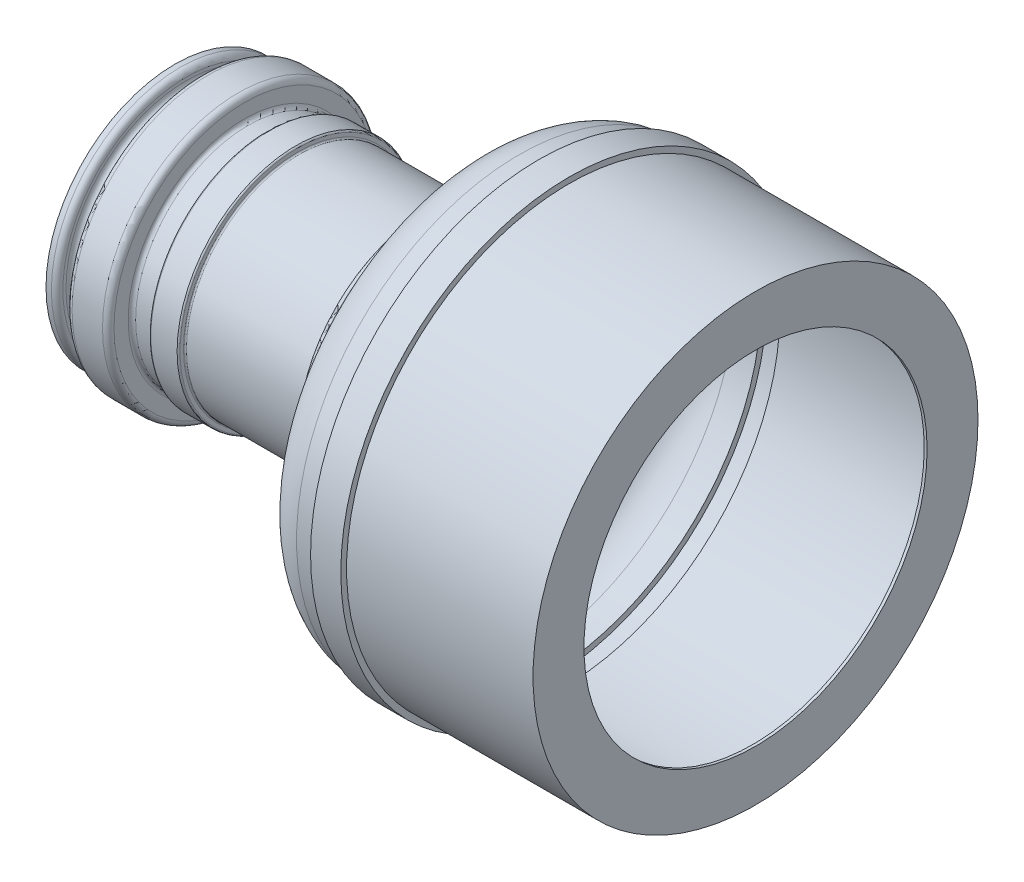
from build123d import *

# Parameters (mm, degrees)
REVOLVE1_ANGLE = 245
REVOLVE2_ANGLE = 245
REVOLVE3_ANGLE = 245
REVOLVE4_ANGLE = 115
SCALE1_SCALE   = 10
SCALE2_SCALE   = 0.75


with BuildPart() as part:
    # Sketch3 → Revolve1 (revolve)
    with BuildSketch(Plane(origin=(0, 0, 0), x_dir=(1, 0, 0), z_dir=(0, 1, 0))):
        with BuildLine():
            Line((18.96, 1.82), (20.82, 1.82))
            Line((20.82, 1.82), (20.82, 22.2))
            Line((20.82, 22.2), (14.72, 22.2))
            ThreePointArc((14.72, 22.2), (13.305786438, 21.614213562), (12.72, 20.2))
            Line((12.72, 20.2), (12.72, 17.4))
            ThreePointArc((12.72, 17.4), (12.134213562, 15.985786438), (10.72, 15.4))
            Line((10.72, 15.4), (-31.78, 15.4))
            ThreePointArc((-31.78, 15.4), (-32.133553391, 15.546446609), (-32.28, 15.9))
            Line((-32.28, 15.9), (-32.28, 17.14))
            ThreePointArc((-32.28, 17.14), (-32.426446609, 17.493553391), (-32.78, 17.64))
            Line((-32.78, 17.64), (-41.88, 17.64))
            ThreePointArc((-41.88, 17.64), (-42.233553391, 17.493553391), (-42.38, 17.14))
            Line((-42.38, 17.14), (-42.38, 16.7))
            ThreePointArc((-42.38, 16.7), (-42.760761184, 15.780761184), (-43.68, 15.4))
            Line((-43.68, 15.4), (-49.42, 15.4))
            ThreePointArc((-49.42, 15.4), (-50.339238816, 15.780761184), (-50.72, 16.7))
            Line((-50.72, 16.7), (-50.72, 21.61))
            ThreePointArc((-50.72, 21.61), (-51.305786438, 23.024213562), (-52.72, 23.61))
            Line((-52.72, 23.61), (-63.27, 23.61))
            ThreePointArc((-63.27, 23.61), (-64.684213562, 23.024213562), (-65.27, 21.61))
            Line((-65.27, 21.61), (-65.27, 18.05))
            ThreePointArc((-65.27, 18.05), (-65.855786438, 16.635786438), (-67.27, 16.05))
            Line((-67.27, 16.05), (-68.95, 16.05))
            ThreePointArc((-68.95, 16.05), (-70.364213562, 16.635786438), (-70.95, 18.05))
            Line((-70.95, 18.05), (-70.95, 19.13))
            ThreePointArc((-70.95, 19.13), (-71.535786438, 20.544213562), (-72.95, 21.13))
            Line((-72.95, 21.13), (-74.81, 21.13))
            Line((-74.81, 21.13), (-74.81, 12.99))
            ThreePointArc((-74.81, 12.99), (-74.663553391, 12.636446609), (-74.31, 12.49))
            Line((-74.31, 12.49), (-61.67, 12.49))
            ThreePointArc((-61.67, 12.49), (-61.316446609, 12.636446609), (-61.17, 12.99))
            Line((-61.17, 12.99), (-61.17, 21.13))
            ThreePointArc((-61.17, 21.13), (-61.023553391, 21.483553391), (-60.67, 21.63))
            Line((-60.67, 21.63), (-55.71, 21.63))
            ThreePointArc((-55.71, 21.63), (-55.356446609, 21.483553391), (-55.21, 21.13))
            Line((-55.21, 21.13), (-55.21, 13.44))
            add(Edge.make_bspline(
                [(18.96, 1.82), (0.219228462, 6.529001303), (-36.593333333, 13.44), (-55.21, 13.44)],
                knots=[0, 0, 0, 0, 1, 1, 1, 1], degree=3))
        make_face()
    revolve(axis=Axis((-68.95, 0, 23.61), (-1, 0, 0)), revolution_arc=REVOLVE1_ANGLE)

    # Sketch11 → Revolve2 (revolve)
    with BuildSketch(Plane(origin=(0, 0, 0), x_dir=(1, 0, 0), z_dir=(0, 1, 0))):
        with BuildLine():
            Line((20.819660629, 1.82), (17.819660629, 1.82))
            Line((17.819660629, 1.82), (16.162595304, 5.072173813))
            Line((16.162595304, 5.072173813), (16.162595304, 23.302173813))
            Line((16.162595304, 23.302173813), (21.792595304, 23.302173813))
            ThreePointArc((21.792595304, 23.302173813), (23.560362257, 24.03440686), (24.292595304, 25.802173813))
            Line((24.292595304, 25.802173813), (24.292595304, 31.172173813))
            ThreePointArc((24.292595304, 31.172173813), (24.731935133, 32.232833985), (25.792595304, 32.672173813))
            Line((25.792595304, 32.672173813), (28.292595304, 32.672173813))
            add(Edge.make_bspline(
                [(28.292595304, 32.672173813), (30.525928638, 32.672173813), (32.765206904, 36.895327773), (35.294936987, 38.868905456), (35.955344806, 40.278541091)],
                knots=[0, 0, 0, 0, 0.572842067, 0.924459008, 0.924459008, 0.924459008, 0.924459008], degree=3))
            ThreePointArc((35.955344806, 40.278541091), (36.508852723, 40.907984012), (37.313666082, 41.142173813))
            Line((37.313666082, 41.142173813), (37.792595304, 41.142173813))
            Line((37.792595304, 41.142173813), (37.792595304, 38.242173813))
            add(Edge.make_bspline(
                [(37.792595304, 38.242173813), (31.613087341, 30.912926982), (28.496481383, 23.355881864), (21.619349027, 7.917786358), (20.819660629, 1.82)],
                knots=[0, 0, 0, 0, 0.47236441, 1, 1, 1, 1], degree=3))
        make_face()
    revolve(axis=Axis((-68.95, 0, 23.61), (-1, 0, 0)), revolution_arc=REVOLVE2_ANGLE)

    # Sketch12 → Revolve3 (revolve)
    with BuildSketch(Plane(origin=(0, 0, 0), x_dir=(1, 0, 0), z_dir=(0, 1, 0))):
        with BuildLine():
            Line((31.757371568, 30.035723068), (31.757371568, 41.535723068))
            ThreePointArc((31.757371568, 41.535723068), (36.748012103, 48.528462974), (44.757371568, 51.635723068))
            Line((44.757371568, 51.635723068), (53.557371568, 51.635723068))
            Line((53.557371568, 51.635723068), (53.557371568, 53.635723068))
            Line((53.557371568, 53.635723068), (60.057371568, 53.635723068))
            Line((60.057371568, 53.635723068), (60.057371568, 51.635723068))
            Line((60.057371568, 51.635723068), (125.807371568, 51.635723068))
            Line((125.807371568, 51.635723068), (125.807371568, 35.965723068))
            Line((125.807371568, 35.965723068), (126.807371568, 35.965723068))
            Line((126.807371568, 35.965723068), (126.807371568, 53.635723068))
            Line((126.807371568, 53.635723068), (62.057371568, 53.635723068))
            Line((62.057371568, 53.635723068), (62.057371568, 55.635723068))
            Line((62.057371568, 55.635723068), (51.557371568, 55.635723068))
            Line((51.557371568, 55.635723068), (51.557371568, 53.635723068))
            Line((51.557371568, 53.635723068), (44.680179001, 53.635723068))
            ThreePointArc((44.680179001, 53.635723068), (35.418473005, 50.027556169), (29.757371568, 41.857489042))
            Line((29.757371568, 41.857489042), (29.757371568, 30.035723068))
            Line((29.757371568, 30.035723068), (31.757371568, 30.035723068))
        make_face()
    revolve(axis=Axis((-68.95, 0, 23.61), (-1, 0, 0)), revolution_arc=REVOLVE3_ANGLE)

    # Sketch34 → Revolve4 (revolve)
    with BuildSketch(Plane(origin=(0, -9.043154651, 19.393107732), x_dir=(-1, 0, 0), z_dir=(0, 0.422618262, -0.906307787))):
        with BuildLine():
            Line((-31.757371573, 63.638720603), (-31.757371568, 63.623740228))
            Line((-31.757371568, 63.623740228), (-31.748347775, 63.623740228))
            add(Edge.make_bspline(
                [(-31.748347775, 63.623740228), (-30.095481955, 60.878546934), (-27.015007616, 53.618253012), (-21.62037509, 41.508106872), (-20.819999996, 35.410603736)],
                knots=[7.4601e-05, 7.4601e-05, 7.4601e-05, 7.4601e-05, 0.256976135, 0.784537124, 0.784537124, 0.784537124, 0.784537124], degree=3))
            Line((-20.819999996, 35.410603736), (-20.82, 35.40801716))
            Line((-20.82, 35.40801716), (-17.819660629, 35.40801716))
            Line((-17.819660629, 35.40801716), (-17.654347142, 35.732463146))
            add(Edge.make_bspline(
                [(-17.654347142, 35.732463146), (1.445037293, 40.427652986), (37.016533042, 47.02801716), (55.21, 47.02801716)],
                knots=[0, 0, 0, 0, 0.977267697, 0.977267697, 0.977267697, 0.977267697], degree=3))
            Line((55.21, 47.02801716), (55.21, 54.71801716))
            ThreePointArc((55.21, 54.71801716), (55.356446609, 55.07157055), (55.71, 55.21801716))
            Line((55.71, 55.21801716), (60.67, 55.21801716))
            ThreePointArc((60.67, 55.21801716), (61.023553391, 55.07157055), (61.17, 54.71801716))
            Line((61.17, 54.71801716), (61.17, 46.57801716))
            ThreePointArc((61.17, 46.57801716), (61.316446609, 46.224463769), (61.67, 46.07801716))
            Line((61.67, 46.07801716), (74.31, 46.07801716))
            ThreePointArc((74.31, 46.07801716), (74.663553391, 46.224463769), (74.81, 46.57801716))
            Line((74.81, 46.57801716), (74.81, 54.71801716))
            Line((74.81, 54.71801716), (72.95, 54.71801716))
            ThreePointArc((72.95, 54.71801716), (71.535786438, 54.132230722), (70.95, 52.71801716))
            Line((70.95, 52.71801716), (70.95, 51.63801716))
            ThreePointArc((70.95, 51.63801716), (70.364213562, 50.223803597), (68.95, 49.63801716))
            Line((68.95, 49.63801716), (67.27, 49.63801716))
            ThreePointArc((67.27, 49.63801716), (65.855786438, 50.223803597), (65.27, 51.63801716))
            Line((65.27, 51.63801716), (65.27, 55.19801716))
            ThreePointArc((65.27, 55.19801716), (64.684213562, 56.612230722), (63.27, 57.19801716))
            Line((63.27, 57.19801716), (52.72, 57.19801716))
            ThreePointArc((52.72, 57.19801716), (51.305786438, 56.612230722), (50.72, 55.19801716))
            Line((50.72, 55.19801716), (50.72, 50.28801716))
            ThreePointArc((50.72, 50.28801716), (50.339238816, 49.368778344), (49.42, 48.98801716))
            Line((49.42, 48.98801716), (43.68, 48.98801716))
            ThreePointArc((43.68, 48.98801716), (42.760761184, 49.368778344), (42.38, 50.28801716))
            Line((42.38, 50.28801716), (42.38, 50.72801716))
            ThreePointArc((42.38, 50.72801716), (42.233553391, 51.08157055), (41.88, 51.22801716))
            Line((41.88, 51.22801716), (32.78, 51.22801716))
            ThreePointArc((32.78, 51.22801716), (32.426446609, 51.08157055), (32.28, 50.72801716))
            Line((32.28, 50.72801716), (32.28, 49.48801716))
            ThreePointArc((32.28, 49.48801716), (32.133553391, 49.134463769), (31.78, 48.98801716))
            Line((31.78, 48.98801716), (-10.72, 48.98801716))
            ThreePointArc((-10.72, 48.98801716), (-12.134213562, 49.573803597), (-12.72, 50.98801716))
            Line((-12.72, 50.98801716), (-12.72, 53.78801716))
            ThreePointArc((-12.72, 53.78801716), (-13.305786438, 55.202230722), (-14.72, 55.78801716))
            Line((-14.72, 55.78801716), (-16.162595304, 55.78801716))
            Line((-16.162595304, 55.78801716), (-16.162595304, 56.890190973))
            Line((-16.162595304, 56.890190973), (-21.792595304, 56.890190973))
            ThreePointArc((-21.792595304, 56.890190973), (-23.560362257, 57.62242402), (-24.292595304, 59.390190973))
            Line((-24.292595304, 59.390190973), (-24.292595304, 64.760190973))
            ThreePointArc((-24.292595304, 64.760190973), (-24.731935133, 65.820851145), (-25.792595304, 66.260190973))
            Line((-25.792595304, 66.260190973), (-28.292595304, 66.260190973))
            add(Edge.make_bspline(
                [(-28.292595304, 66.260190973), (-28.824520778, 66.260190973), (-29.308468193, 66.408640439), (-29.757371568, 66.6585119)],
                knots=[0.788022014, 0.788022014, 0.788022014, 0.788022014, 0.924459008, 0.924459008, 0.924459008, 0.924459008], degree=3))
            Line((-29.757371568, 66.6585119), (-29.757371568, 75.445506202))
            ThreePointArc((-29.757371568, 75.445506202), (-35.418473005, 83.615573329), (-44.680179001, 87.223740228))
            Line((-44.680179001, 87.223740228), (-51.557371568, 87.223740228))
            Line((-51.557371568, 87.223740228), (-51.557371568, 89.223740228))
            Line((-51.557371568, 89.223740228), (-62.057371568, 89.223740228))
            Line((-62.057371568, 89.223740228), (-62.057371568, 87.223740228))
            Line((-62.057371568, 87.223740228), (-126.807371568, 87.223740228))
            Line((-126.807371568, 87.223740228), (-126.807371568, 69.553740228))
            Line((-126.807371568, 69.553740228), (-125.807371568, 69.553740228))
            Line((-125.807371568, 69.553740228), (-125.807371568, 85.223740228))
            Line((-125.807371568, 85.223740228), (-60.057371568, 85.223740228))
            Line((-60.057371568, 85.223740228), (-60.057371568, 87.223740228))
            Line((-60.057371568, 87.223740228), (-53.557371568, 87.223740228))
            Line((-53.557371568, 87.223740228), (-53.557371568, 85.223740228))
            Line((-53.557371568, 85.223740228), (-44.757371568, 85.223740228))
            ThreePointArc((-44.757371568, 85.223740228), (-36.748012103, 82.116480134), (-31.757371568, 75.123740228))
            Line((-31.757371568, 75.123740228), (-31.757371568, 68.519985142))
            add(Edge.make_bspline(
                [(-31.757371568, 68.519985142), (-32.325731706, 69.224864017), (-33.75663368, 71.256809965), (-35.294936987, 72.456922616), (-35.955344806, 73.866558251)],
                knots=[0, 0, 0, 0, 0.210537242, 0.562154184, 0.562154184, 0.562154184, 0.562154184], degree=3))
            ThreePointArc((-35.955344806, 73.866558251), (-36.508852723, 74.496001171), (-37.313666082, 74.730190973))
            Line((-37.313666082, 74.730190973), (-37.792595304, 74.730190973))
            Line((-37.792595304, 74.730190973), (-37.792595304, 71.830190973))
            add(Edge.make_bspline(
                [(-37.792595304, 71.830190973), (-34.980004955, 68.494299341), (-33.142584325, 65.937238438), (-31.757371573, 63.638720603)],
                knots=[0.78500431, 0.78500431, 0.78500431, 0.78500431, 1, 1, 1, 1], degree=3))
        make_face()
    revolve(axis=Axis((-68.95, 0, 23.61), (-1, 0, 0)), revolution_arc=REVOLVE4_ANGLE)


with BuildPart() as part_1:
    # Scale1: scaled about (0, 0, 0)
    add(part.part.scale(SCALE1_SCALE))


with BuildPart() as part_2:
    # Scale2: scaled about (0, 0, 0)
    add(part_1.part.scale(SCALE2_SCALE))


solid = part_2.part
